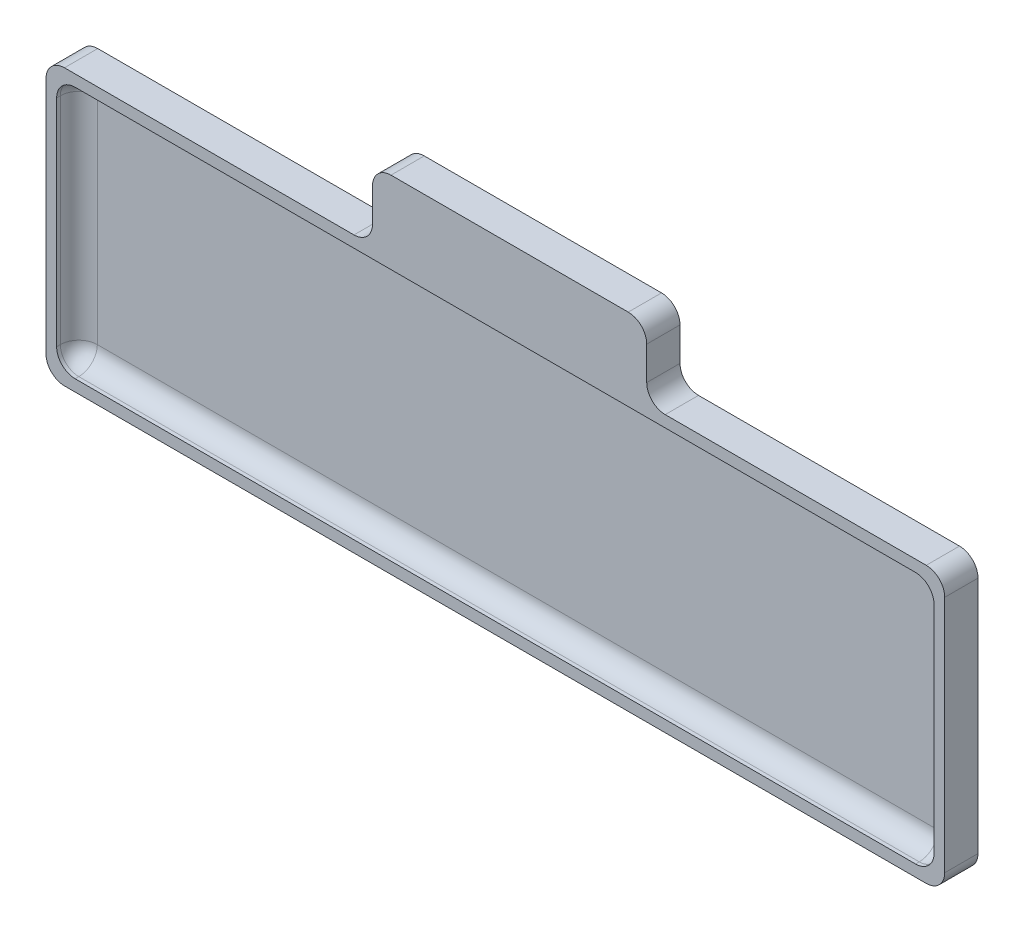
from build123d import *

# Parameters (mm, degrees)
SKETCH2_W           = 243
SKETCH2_H           = 74.5
BOSS_EXTRUDE1_DEPTH = 3
SKETCH2_3_W         = 243
SKETCH2_3_H         = 74.5
SKETCH2_3_W_2       = 237.244602054
SKETCH2_3_H_2       = 68.264985558
BOSS_EXTRUDE2_DEPTH = 9
SKETCH3_W           = 74.150238013
SKETCH3_H           = 9
BOSS_EXTRUDE4_DEPTH = 19
FILLET1_R           = 5


with BuildPart() as part:
    # Sketch2 → Boss-Extrude1 (new body)
    with BuildSketch(Plane.XY):
        with Locations((3.706779661, 48.692372881)):
            Rectangle(SKETCH2_W, SKETCH2_H)
    extrude(amount=BOSS_EXTRUDE1_DEPTH)

    # Sketch2_3 → Boss-Extrude2 (add)
    with BuildSketch(Plane.XY):
        with Locations((3.706779661, 48.692372881)):
            Rectangle(SKETCH2_3_W, SKETCH2_3_H)
        with Locations((3.706779661, 48.692372881)):
            Rectangle(SKETCH2_3_W_2, SKETCH2_3_H_2, mode=Mode.SUBTRACT)
    extrude(amount=BOSS_EXTRUDE2_DEPTH)

    # Sketch3 → Boss-Extrude4 (add)
    with BuildSketch(Plane(origin=(0, 85.942372881, 0), x_dir=(1, 0, 0), z_dir=(0, 1, 0))):
        with Locations((7.559560342, -4.5)):
            Rectangle(SKETCH3_W, SKETCH3_H)
    extrude(amount=BOSS_EXTRUDE4_DEPTH)

    # Fillet1
    fillet1_edges = [part.edges().sort_by_distance(p)[0] for p in [
        (3.706779661, 82.82486566, 3),
        (-114.915521366, 48.692372881, 3),
        (3.706779661, 14.559880102, 3),
        (122.329080688, 48.692372881, 3),
        (44.634679348, 85.942372881, 4.5),
        (-29.515558665, 85.942372881, 4.5),
        (-29.515558665, 104.942372881, 4.5),
        (44.634679348, 104.942372881, 4.5),
        (122.329080688, 82.82486566, 6),
        (125.206779661, 85.942372881, 4.5),
        (122.329080688, 14.559880102, 6),
        (125.206779661, 11.442372881, 4.5),
        (-114.915521366, 14.559880102, 6),
        (-114.915521366, 82.82486566, 6),
        (-117.793220339, 11.442372881, 4.5),
        (-117.793220339, 85.942372881, 4.5),
    ]]
    fillet(fillet1_edges, radius=FILLET1_R)


solid = part.part
